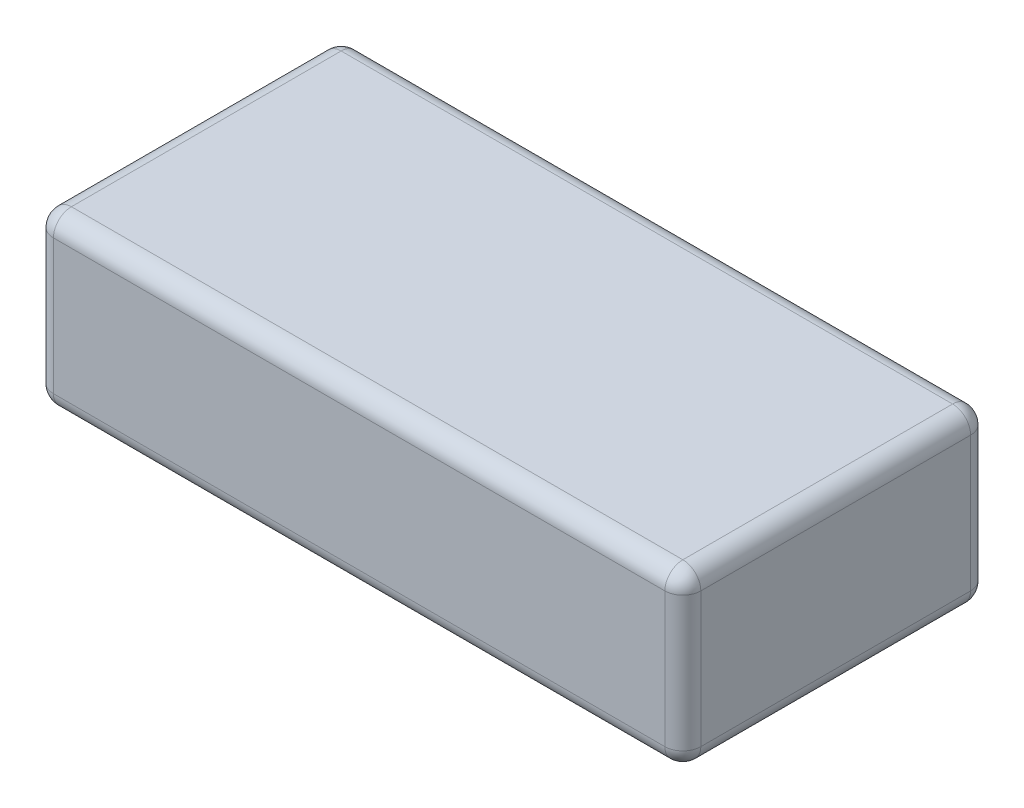
from build123d import *

# Parameters (mm, degrees)
SKETCH1_W           = 72
SKETCH1_H           = 34
BOSS_EXTRUDE1_DEPTH = 19
FILLET1_R           = 2


with BuildPart() as part:
    # Sketch1 → Boss-Extrude1 (new body)
    with BuildSketch(Plane(origin=(0, 0, 0), x_dir=(1, 0, 0), z_dir=(0, 1, 0))):
        Rectangle(SKETCH1_W, SKETCH1_H)
    extrude(amount=BOSS_EXTRUDE1_DEPTH)

    # Fillet1
    fillet1_edges = [part.edges().sort_by_distance(p)[0] for p in [
        (-36, 19, 0),
        (0, 19, 17),
        (36, 19, 0),
        (0, 0, 17),
        (-36, 0, 0),
        (0, 0, -17),
        (36, 0, 0),
        (36, 9.5, 17),
        (-36, 9.5, 17),
        (-36, 9.5, -17),
        (36, 9.5, -17),
        (0, 19, -17),
    ]]
    fillet(fillet1_edges, radius=FILLET1_R)


solid = part.part
